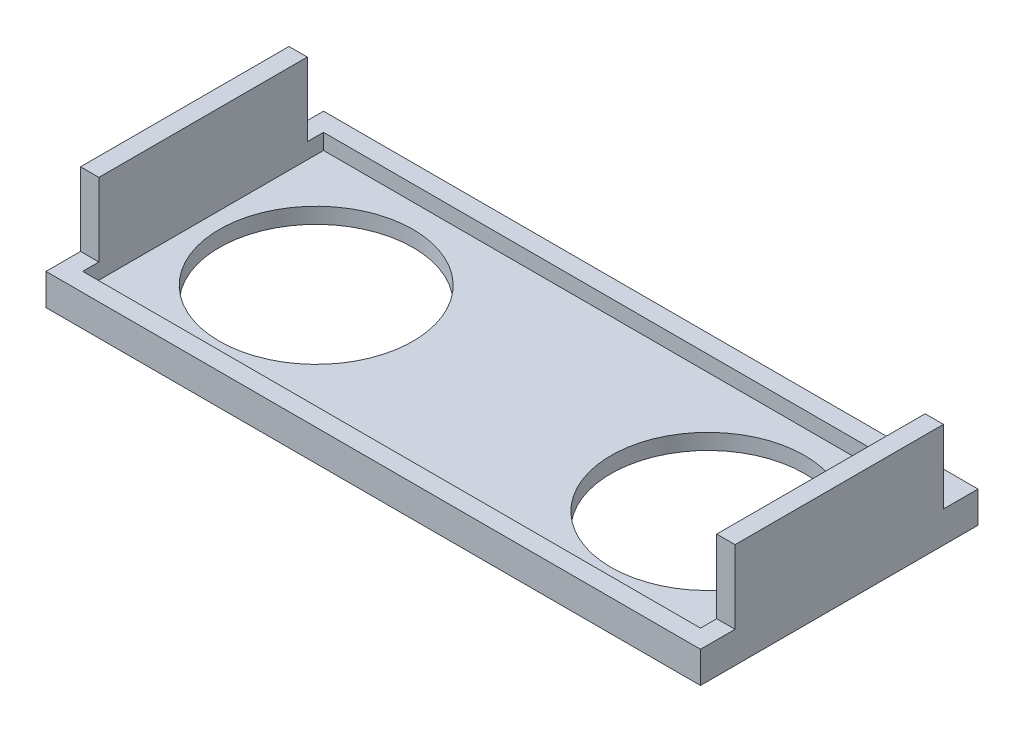
from build123d import *

# Parameters (mm, degrees)
CROQUIS1_W              = 62.5
CROQUIS1_H              = 26.5
SALIENTE_EXTRUIR1_DEPTH = 1.5
CORTAR_EXTRUIR1_START   = 1.5
CROQUIS4_W              = 59
CROQUIS4_H              = 23
CORTAR_EXTRUIR1_DEPTH   = 1.5
CROQUIS5_R              = 9.25
CORTAR_EXTRUIR2_DEPTH   = 1.5
SALIENTE_EXTRUIR2_START = 31.25
CROQUIS6_W              = 19.9
CROQUIS6_H              = 10
SALIENTE_EXTRUIR2_DEPTH = 1.75
SALIENTE_EXTRUIR3_START = -31.25
CROQUIS6_3_W            = 19.9
CROQUIS6_3_H            = 10
SALIENTE_EXTRUIR3_DEPTH = 1.75


with BuildPart() as part:
    # Croquis1 → Saliente-Extruir1 (new body, symmetric)
    with BuildSketch(Plane(origin=(0, 0, 0), x_dir=(1, 0, 0), z_dir=(0, 1, 0))):
        Rectangle(CROQUIS1_W, CROQUIS1_H)
    extrude(amount=SALIENTE_EXTRUIR1_DEPTH, both=True)

    # Croquis4 → Cortar-Extruir1 (cut)
    with BuildSketch(Plane(origin=(0, 0, 0), x_dir=(1, 0, 0), z_dir=(0, 1, 0)).offset(CORTAR_EXTRUIR1_START)):
        Rectangle(CROQUIS4_W, CROQUIS4_H)
    extrude(amount=-CORTAR_EXTRUIR1_DEPTH, mode=Mode.SUBTRACT)

    # Croquis5 → Cortar-Extruir2 (cut)
    with BuildSketch(Plane(origin=(0, 0, 0), x_dir=(1, 0, 0), z_dir=(0, 1, 0))):
        with Locations((-18.7, 0)):
            Circle(CROQUIS5_R)
        with Locations((18.7, 0)):
            Circle(CROQUIS5_R)
    extrude(amount=-CORTAR_EXTRUIR2_DEPTH, mode=Mode.SUBTRACT)

    # Croquis6 → Saliente-Extruir2 (add)
    with BuildSketch(Plane(origin=(0, 0, 0), x_dir=(0, 0, -1), z_dir=(1, 0, 0)).offset(SALIENTE_EXTRUIR2_START)):
        with Locations((0, 3.5)):
            Rectangle(CROQUIS6_W, CROQUIS6_H)
    extrude(amount=-SALIENTE_EXTRUIR2_DEPTH)

    # Croquis6_3 → Saliente-Extruir3 (add)
    with BuildSketch(Plane(origin=(0, 0, 0), x_dir=(0, 0, -1), z_dir=(1, 0, 0)).offset(SALIENTE_EXTRUIR3_START)):
        with Locations((0, 3.5)):
            Rectangle(CROQUIS6_3_W, CROQUIS6_3_H)
    extrude(amount=SALIENTE_EXTRUIR3_DEPTH)


solid = part.part
